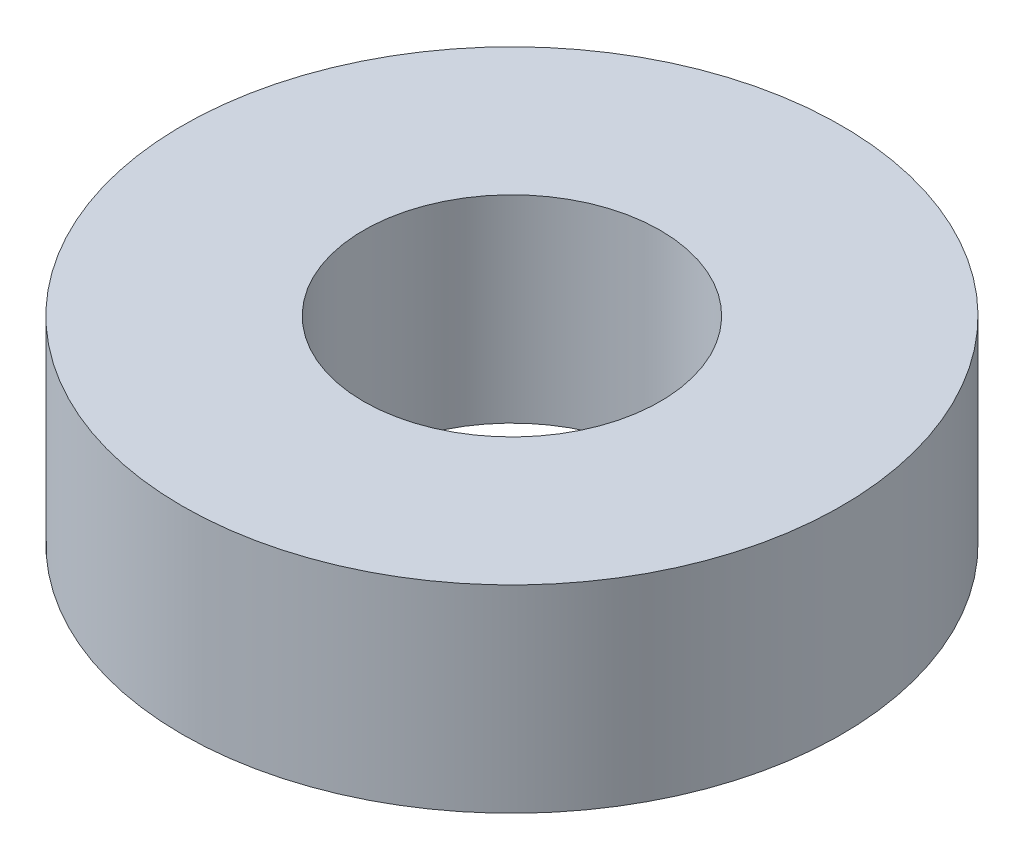
from build123d import *

# Parameters (mm, degrees)
SKETCH1_R            = 5
BOSS_EXTRUDE1_DEPTH  = 3
M4_CLEARANCE_HOLE1_D = 4.5


with BuildPart() as part:
    # Sketch1 → Boss-Extrude1 (new body)
    with BuildSketch(Plane(origin=(0, 0, 0), x_dir=(1, 0, 0), z_dir=(0, 1, 0))):
        Circle(SKETCH1_R)
    extrude(amount=BOSS_EXTRUDE1_DEPTH)

    # M4 Clearance Hole1 (through all)
    with Locations(Plane(origin=(0, 3, 0), x_dir=(1, 0, 0), z_dir=(0, 1, 0))):
        with Locations((0, 0)):
            Hole(M4_CLEARANCE_HOLE1_D / 2)


solid = part.part
